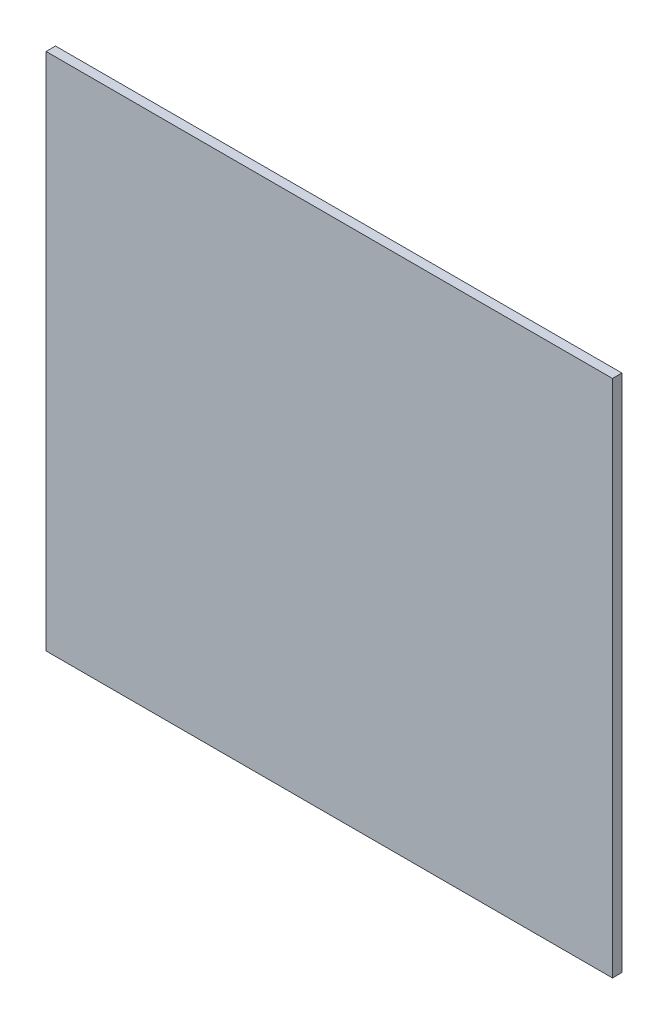
from build123d import *

# Parameters (mm, degrees)
ESQUISSE1_W        = 600
ESQUISSE1_H        = 550
BOSS_EXTRU_1_DEPTH = 10


with BuildPart() as part:
    # Esquisse1 → Boss.-Extru.1 (new body)
    with BuildSketch(Plane.XY):
        with Locations((300, 275)):
            Rectangle(ESQUISSE1_W, ESQUISSE1_H)
    extrude(amount=BOSS_EXTRU_1_DEPTH)


solid = part.part
